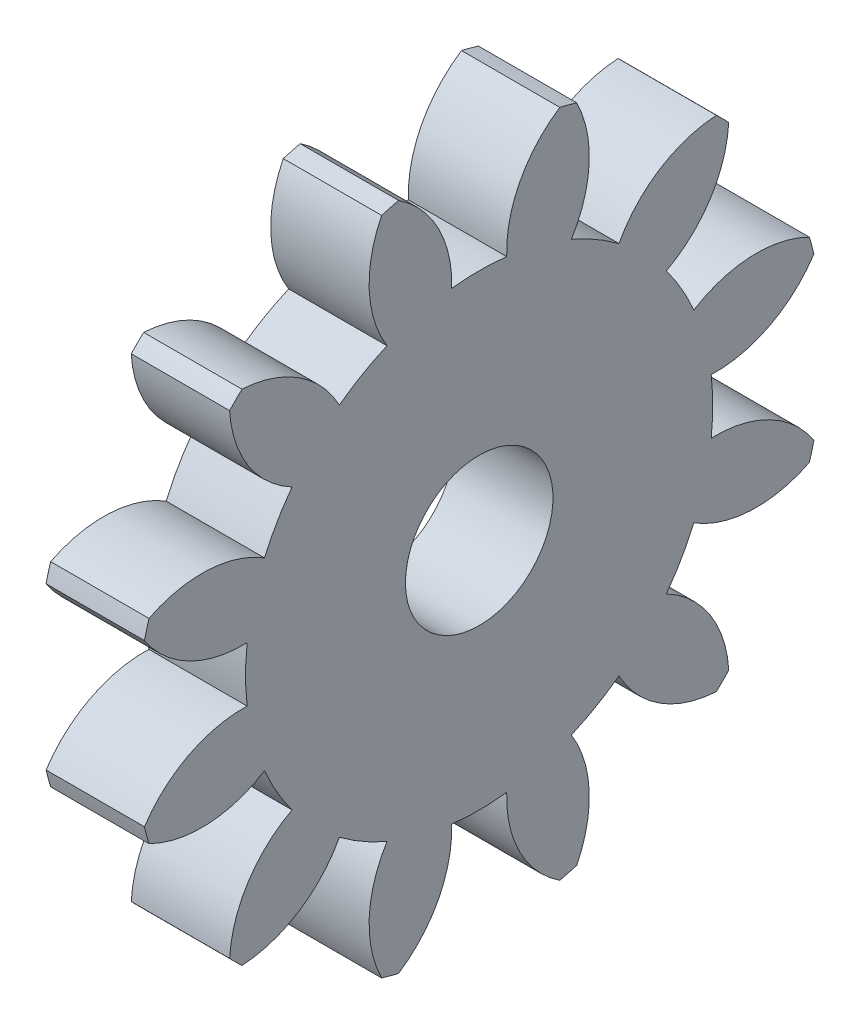
from build123d import *

# Parameters (mm, degrees)
BASPROSKE_W     = 12.7
BASPROSKE_H     = 44.45
TOOTHCUT_DEPTH  = 65.131856359
TEETHCUTS_COUNT = 12
TEETHCUTS_ANGLE = 330
BORSKE_R        = 9.525
BORE_DEPTH      = 25.4000508


with BuildPart() as part:
    # BasProSke → Base-Revolve (revolve)
    with BuildSketch(Plane(origin=(0, 0, 0), x_dir=(1, 0, 0), z_dir=(0, 1, 0)), mode=Mode.PRIVATE) as base_revolve_sk:
        with Locations((6.35, 22.225)):
            Rectangle(BASPROSKE_W, BASPROSKE_H)
    revolve(base_revolve_sk.sketch.rotate(Axis((-10, 0, 0), (1, 0, 0)), 180), axis=Axis((-10, 0, 0), (1, 0, 0)))

    # TooCutSke → ToothCut (cut, through all)
    with BuildSketch(Plane(origin=(0, 0, 0), x_dir=(0, 0, -1), z_dir=(1, 0, 0))):
        with BuildLine():
            ThreePointArc((3.552242783, 29.951316604), (0, 30.16123), (-3.552242783, 29.951316604))
            ThreePointArc((-3.552242783, 29.951316604), (-5.254049238, 37.49538421), (-10.439744342, 43.232776261))
            ThreePointArc((-10.439744342, 43.232776261), (0, 44.4754), (10.439744342, 43.232776261))
            ThreePointArc((10.439744342, 43.232776261), (5.254049238, 37.49538421), (3.552242783, 29.951316604))
        make_face()
    toothcut = extrude(amount=TOOTHCUT_DEPTH, mode=Mode.SUBTRACT)

    # TeethCuts: ToothCut ×12 about axis
    teethcuts_axis = Axis((-10, 0, 0), (1, 0, 0))
    for i in range(1, TEETHCUTS_COUNT):
        add(toothcut.rotate(teethcuts_axis, i * TEETHCUTS_ANGLE / (TEETHCUTS_COUNT - 1)), mode=Mode.SUBTRACT)

    # BorSke → Bore (cut, symmetric)
    with BuildSketch(Plane(origin=(0, 0, 0), x_dir=(0, 0, -1), z_dir=(1, 0, 0))):
        with Locations(Location((0, 0, 0), (0, 0, 180))):
            Circle(BORSKE_R)
    extrude(amount=BORE_DEPTH, both=True, mode=Mode.SUBTRACT)


solid = part.part
